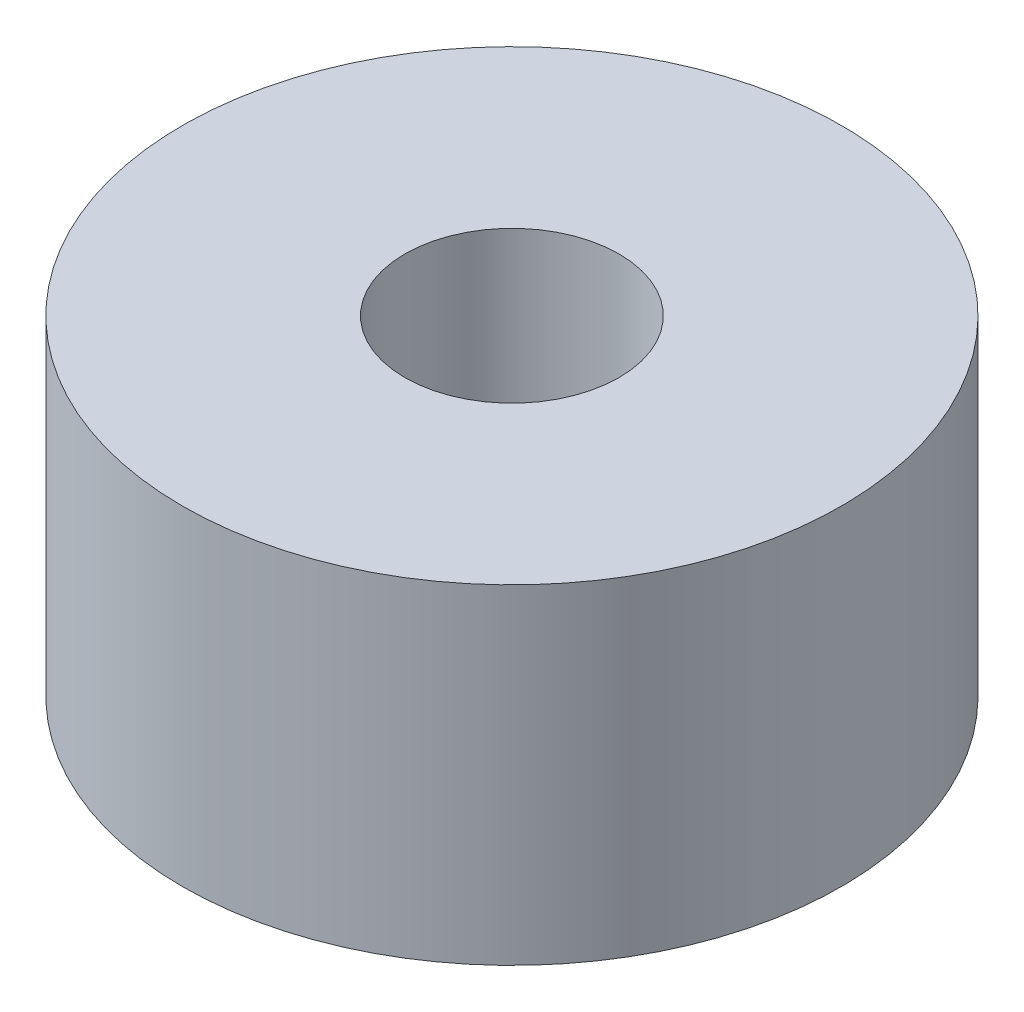
from build123d import *

# Parameters (mm, degrees)
ESBO_O1_R                = 10
ESBO_O1_R_2              = 3.25
RESSALTO_EXTRUS_O1_DEPTH = 10


with BuildPart() as part:
    # Esboço1 → Ressalto-extrusão1 (new body)
    with BuildSketch(Plane(origin=(0, 0, 0), x_dir=(1, 0, 0), z_dir=(0, 1, 0))):
        Circle(ESBO_O1_R)
        Circle(ESBO_O1_R_2, mode=Mode.SUBTRACT)
    extrude(amount=RESSALTO_EXTRUS_O1_DEPTH)


solid = part.part
